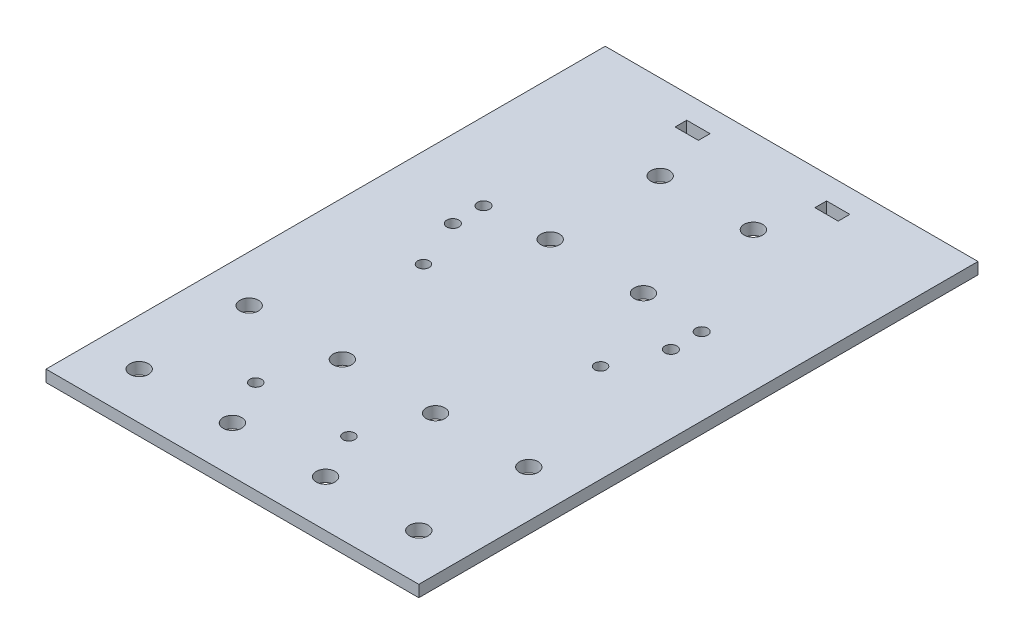
from build123d import *

# Parameters (mm, degrees)
SKETCH2_W           = 101.6
SKETCH2_H           = 152.4
BOSS_EXTRUDE1_DEPTH = 3.175
SKETCH3_R           = 2.54
CUT_EXTRUDE1_DEPTH  = 4.175
SKETCH4_R           = 1.651
CUT_EXTRUDE2_DEPTH  = 4.175
SKETCH5_R           = 1.5875
CUT_EXTRUDE3_DEPTH  = 4.175
SKETCH6_W           = 6.35
SKETCH6_H           = 3.175
CUT_EXTRUDE4_DEPTH  = 4.175


with BuildPart() as part:
    # Sketch2 → Boss-Extrude1 (new body)
    with BuildSketch(Plane(origin=(0, 0, 0), x_dir=(1, 0, 0), z_dir=(0, 1, 0))):
        Rectangle(SKETCH2_W, SKETCH2_H)
    extrude(amount=BOSS_EXTRUDE1_DEPTH)

    # Sketch3 → Cut-Extrude1 (cut, through all)
    with BuildSketch(Plane(origin=(0, 3.175, 0), x_dir=(1, 0, 0), z_dir=(0, 1, 0))):
        with Locations((-38.1, -63.5)):
            Circle(SKETCH3_R)
        with Locations((-12.7, -63.5)):
            Circle(SKETCH3_R)
        with Locations((12.7, -63.5)):
            Circle(SKETCH3_R)
        with Locations((38.1, -63.5)):
            Circle(SKETCH3_R)
        with Locations((-38.1, -33.528)):
            Circle(SKETCH3_R)
        with Locations((-12.7, -33.528)):
            Circle(SKETCH3_R)
        with Locations((12.7, -33.528)):
            Circle(SKETCH3_R)
        with Locations((38.1, -33.528)):
            Circle(SKETCH3_R)
        with Locations((-12.7, 53.086)):
            Circle(SKETCH3_R)
        with Locations((-12.7, 23.114)):
            Circle(SKETCH3_R)
        with Locations((12.7, 23.114)):
            Circle(SKETCH3_R)
        with Locations((12.7, 53.086)):
            Circle(SKETCH3_R)
    extrude(amount=-CUT_EXTRUDE1_DEPTH, mode=Mode.SUBTRACT)

    # Sketch4 → Cut-Extrude2 (cut, through all)
    with BuildSketch(Plane(origin=(0, 3.175, 0), x_dir=(1, 0, 0), z_dir=(0, 1, 0))):
        with Locations((29.718, 13.589)):
            Circle(SKETCH4_R)
        with Locations((29.718, 21.971)):
            Circle(SKETCH4_R)
        with Locations((-29.718, 21.971)):
            Circle(SKETCH4_R)
        with Locations((-29.718, 13.589)):
            Circle(SKETCH4_R)
    extrude(amount=-CUT_EXTRUDE2_DEPTH, mode=Mode.SUBTRACT)

    # Sketch5 → Cut-Extrude3 (cut, through all)
    with BuildSketch(Plane(origin=(0, 3.175, 0), x_dir=(1, 0, 0), z_dir=(0, 1, 0))):
        with Locations((-24.13, 0)):
            Circle(SKETCH5_R)
        with Locations((24.13, 0)):
            Circle(SKETCH5_R)
        with Locations((-19.05, -50.8)):
            Circle(SKETCH5_R)
        with Locations((6.35, -50.8)):
            Circle(SKETCH5_R)
    extrude(amount=-CUT_EXTRUDE3_DEPTH, mode=Mode.SUBTRACT)

    # Sketch6 → Cut-Extrude4 (cut, through all)
    with BuildSketch(Plane(origin=(0, 3.175, 0), x_dir=(1, 0, 0), z_dir=(0, 1, 0))):
        with Locations((19.05, 68.2625)):
            Rectangle(SKETCH6_W, SKETCH6_H)
        with Locations((-19.05, 68.2625)):
            Rectangle(SKETCH6_W, SKETCH6_H)
    extrude(amount=-CUT_EXTRUDE4_DEPTH, mode=Mode.SUBTRACT)


solid = part.part
